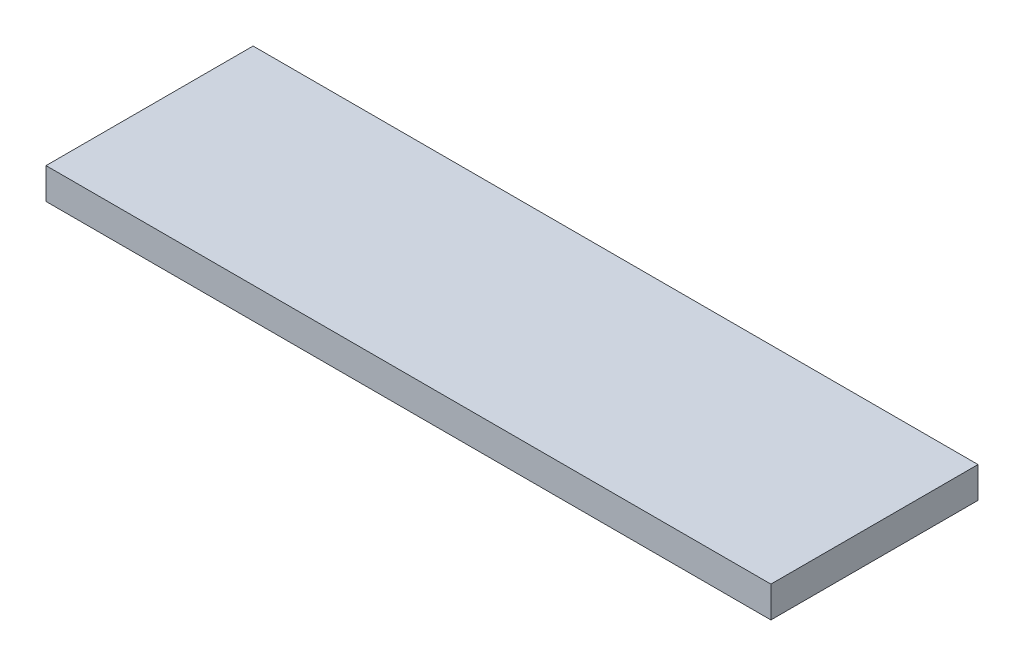
from build123d import *

# Parameters (mm, degrees)
SKETCH_1_W      = 70
SKETCH_1_H      = 20
EXTRUDE_1_DEPTH = 3


with BuildPart() as part:
    # Эскиз1 → Бобышка-Вытянуть1 (new body)
    with BuildSketch(Plane(origin=(0, 0, 0), x_dir=(1, 0, 0), z_dir=(0, 1, 0))):
        with Locations((35, 10)):
            Rectangle(SKETCH_1_W, SKETCH_1_H)
    extrude(amount=EXTRUDE_1_DEPTH)


solid = part.part
